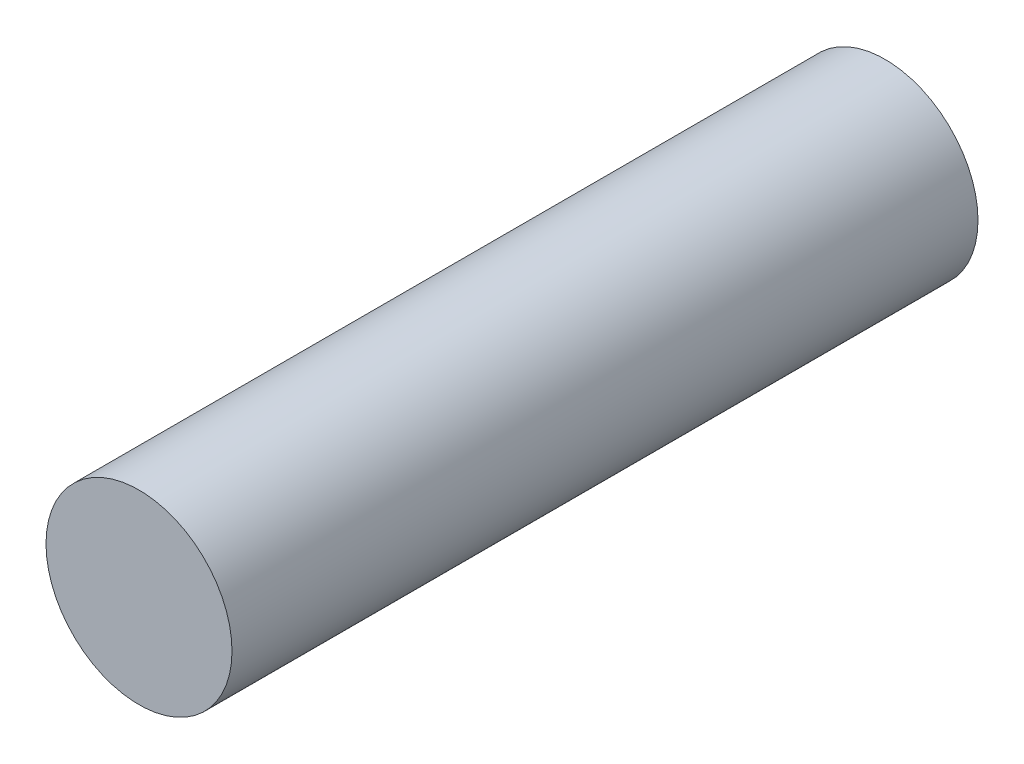
from build123d import *

# Parameters (mm, degrees)
SKETCH1_R           = 2.3749
BOSS_EXTRUDE1_DEPTH = 19.05


with BuildPart() as part:
    # Sketch1 → Boss-Extrude1 (new body)
    with BuildSketch(Plane.XY):
        Circle(SKETCH1_R)
    extrude(amount=BOSS_EXTRUDE1_DEPTH)


solid = part.part
